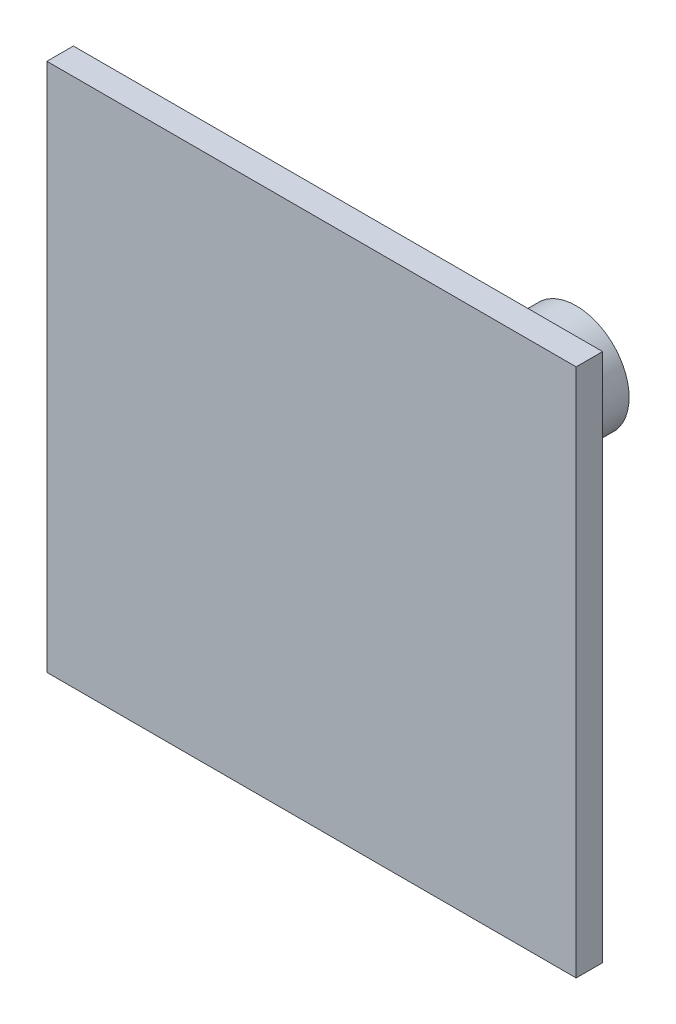
from build123d import *

# Parameters (mm, degrees)
SKETCH1_W           = 200
SKETCH1_H           = 200
BOSS_EXTRUDE1_DEPTH = 10
SKETCH2_R           = 20
BOSS_EXTRUDE2_DEPTH = 90


with BuildPart() as part:
    # Sketch1 → Boss-Extrude1 (new body)
    with BuildSketch(Plane.XY):
        with Locations((-2.425876011, -32.884097035)):
            Rectangle(SKETCH1_W, SKETCH1_H)
    extrude(amount=BOSS_EXTRUDE1_DEPTH)

    # Sketch2 → Boss-Extrude2 (add)
    with BuildSketch(Plane(origin=(0, 0, 0), x_dir=(-1, 0, 0), z_dir=(0, 0, -1))):
        with Locations((2.425876011, -32.884097035)):
            Circle(SKETCH2_R)
    extrude(amount=BOSS_EXTRUDE2_DEPTH)


solid = part.part
